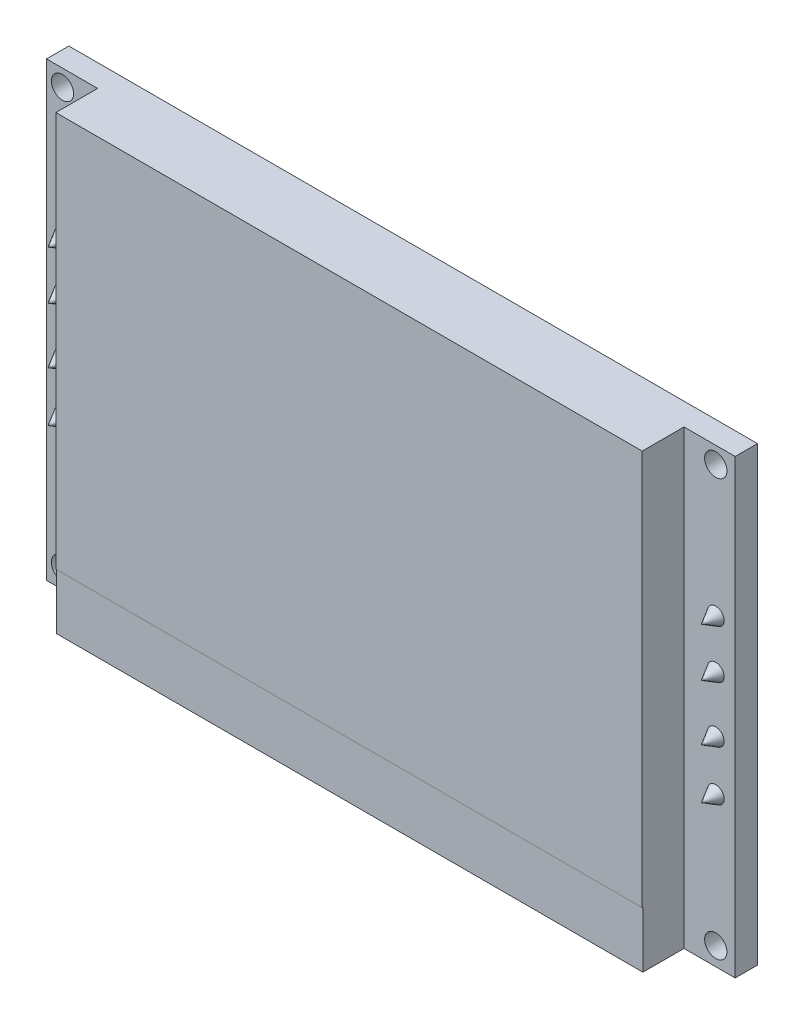
from build123d import *

# Parameters (mm, degrees)
ESQUISSE1_W             = 49.4
ESQUISSE1_H             = 32.4
BOSS_EXTRU_1_DEPTH      = 1.6
ESQUISSE5_W             = 42.06
ESQUISSE5_H             = 32.4
BOSS_EXTRU_2_DEPTH      = 3
ESQUISSE6_R             = 0.8
ENL_V_MAT_EXTRU_1_DEPTH = 3
ESQUISSE7_W             = 42.06
ESQUISSE7_H             = 4.035624865
ENL_V_MAT_EXTRU_2_DEPTH = 0.05
ESQUISSE8_R             = 0.6
BOSS_EXTRU_3_DEPTH      = 1.2
BOSS_EXTRU_3_TAPER      = 30


with BuildPart() as part:
    # Esquisse1 → Boss.-Extru.1 (new body)
    with BuildSketch(Plane.XY):
        with Locations((24.7, 16.2)):
            Rectangle(ESQUISSE1_W, ESQUISSE1_H)
    extrude(amount=BOSS_EXTRU_1_DEPTH)

    # Esquisse5 → Boss.-Extru.2 (add)
    with BuildSketch(Plane.XY.offset(1.6)):
        with Locations((24.7, 16.2)):
            Rectangle(ESQUISSE5_W, ESQUISSE5_H)
    extrude(amount=BOSS_EXTRU_2_DEPTH)

    # Esquisse6 → Enlèv. mat.-Extru.1 (cut)
    with BuildSketch(Plane.XY.offset(1.6)):
        with Locations((1.144377661, 31.203769118)):
            Circle(ESQUISSE6_R)
        with Locations((1.144377661, 1.31386178)):
            Circle(ESQUISSE6_R)
        with Locations((48.008189331, 1.31386178)):
            Circle(ESQUISSE6_R)
        with Locations((48.008189331, 31.203769118)):
            Circle(ESQUISSE6_R)
    extrude(amount=-ENL_V_MAT_EXTRU_1_DEPTH, mode=Mode.SUBTRACT)

    # Esquisse7 → Enlèv. mat.-Extru.2 (cut)
    with BuildSketch(Plane.XY.offset(4.6)):
        with Locations((24.7, 2.017812432)):
            Rectangle(ESQUISSE7_W, ESQUISSE7_H)
    extrude(amount=-ENL_V_MAT_EXTRU_2_DEPTH, mode=Mode.SUBTRACT)

    # Esquisse8 → Boss.-Extru.3 (add)
    with BuildSketch(Plane.XY.offset(1.6)):
        with Locations((1.144377661, 21.803769118)):
            Circle(ESQUISSE8_R)
        with Locations((1.144377661, 10.71386178)):
            Circle(ESQUISSE8_R)
        with Locations((48.008189331, 21.803769118)):
            Circle(ESQUISSE8_R)
        with Locations((48.008189331, 10.71386178)):
            Circle(ESQUISSE8_R)
        with Locations((1.144377661, 18.315710158)):
            Circle(ESQUISSE8_R)
        with Locations((1.144377661, 14.305919008)):
            Circle(ESQUISSE8_R)
        with Locations((48.008189331, 18.315710158)):
            Circle(ESQUISSE8_R)
        with Locations((48.008189331, 14.305919008)):
            Circle(ESQUISSE8_R)
    extrude(amount=BOSS_EXTRU_3_DEPTH, taper=BOSS_EXTRU_3_TAPER)


solid = part.part
